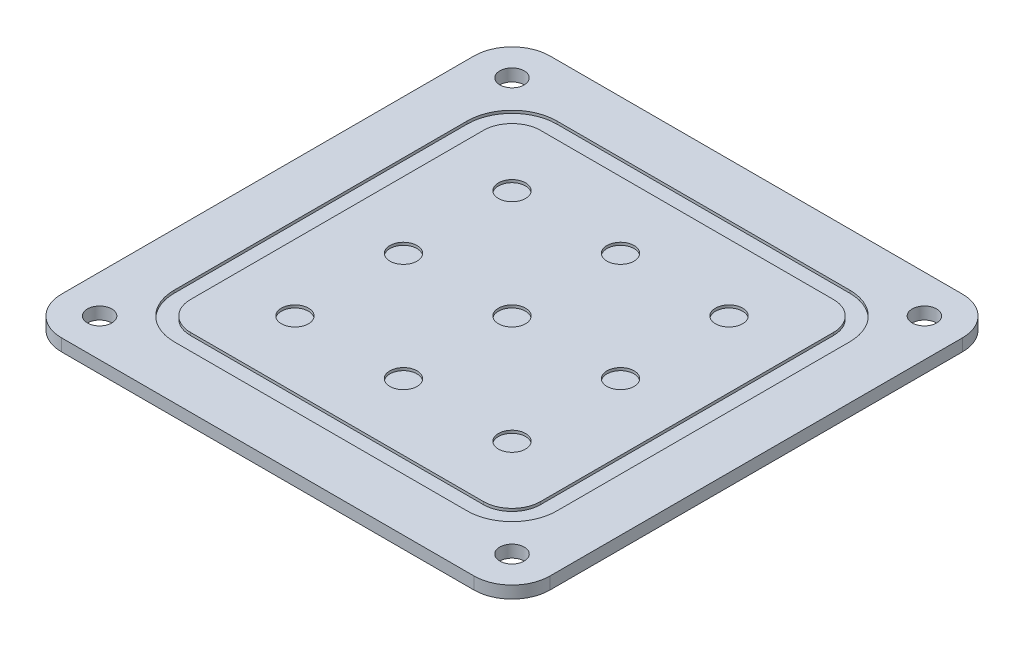
from build123d import *

# Parameters (mm, degrees)
SKETCH1_W            = 90
SKETCH1_H            = 90
BOSS_EXTRUDE1_DEPTH  = 2.25
SKETCH2_R            = 2.5
CUT_EXTRUDE1_DEPTH   = 0.5
FILLET1_R            = 7
M4_CLEARANCE_HOLE1_D = 4.5


with BuildPart() as part:
    # Sketch1 → Boss-Extrude1 (new body)
    with BuildSketch(Plane(origin=(0, 0, 0), x_dir=(1, 0, 0), z_dir=(0, 1, 0))):
        Rectangle(SKETCH1_W, SKETCH1_H)
    extrude(amount=BOSS_EXTRUDE1_DEPTH)

    # Sketch2 → Cut-Extrude1 (cut)
    with BuildSketch(Plane(origin=(0, 2.25, 0), x_dir=(1, 0, 0), z_dir=(0, 1, 0))):
        with BuildLine():
            ThreePointArc((-35.25, 27), (-32.833630945, 32.833630945), (-27, 35.25))
            Line((-27, 35.25), (27, 35.25))
            ThreePointArc((27, 35.25), (32.833630945, 32.833630945), (35.25, 27))
            Line((35.25, 27), (35.25, -27))
            ThreePointArc((35.25, -27), (32.833630945, -32.833630945), (27, -35.25))
            Line((27, -35.25), (-27, -35.25))
            ThreePointArc((-27, -35.25), (-32.833630945, -32.833630945), (-35.25, -27))
            Line((-35.25, -27), (-35.25, 27))
        make_face()
        with BuildLine():
            Line((-27, -32.25), (27, -32.25))
            ThreePointArc((27, -32.25), (30.712310601, -30.712310601), (32.25, -27))
            Line((32.25, -27), (32.25, 27))
            ThreePointArc((32.25, 27), (30.712310601, 30.712310601), (27, 32.25))
            Line((27, 32.25), (-27, 32.25))
            ThreePointArc((-27, 32.25), (-30.712310601, 30.712310601), (-32.25, 27))
            Line((-32.25, 27), (-32.25, -27))
            ThreePointArc((-32.25, -27), (-30.712310601, -30.712310601), (-27, -32.25))
        make_face(mode=Mode.SUBTRACT)
        with Locations((-20, 20)):
            Circle(SKETCH2_R)
        with Locations((0, 20)):
            Circle(SKETCH2_R)
        with Locations((20, 20)):
            Circle(SKETCH2_R)
        with Locations((20, 0)):
            Circle(SKETCH2_R)
        with Locations((20, -20)):
            Circle(SKETCH2_R)
        with Locations((0, -20)):
            Circle(SKETCH2_R)
        Circle(SKETCH2_R)
        with Locations((-20, 0)):
            Circle(SKETCH2_R)
        with Locations((-20, -20)):
            Circle(SKETCH2_R)
    extrude(amount=-CUT_EXTRUDE1_DEPTH, mode=Mode.SUBTRACT)

    # Fillet1
    fillet1_edges = [part.edges().sort_by_distance(p)[0] for p in [
        (45, 1.125, 45),
        (-45, 1.125, 45),
        (-45, 1.125, -45),
        (45, 1.125, -45),
    ]]
    fillet(fillet1_edges, radius=FILLET1_R)

    # M4 Clearance Hole1 (through all)
    with Locations(Plane(origin=(0, 2.25, 0), x_dir=(1, 0, 0), z_dir=(0, 1, 0))):
        with Locations((-38, 38), (38, 38), (38, -38), (-38, -38)):
            Hole(M4_CLEARANCE_HOLE1_D / 2)


solid = part.part
